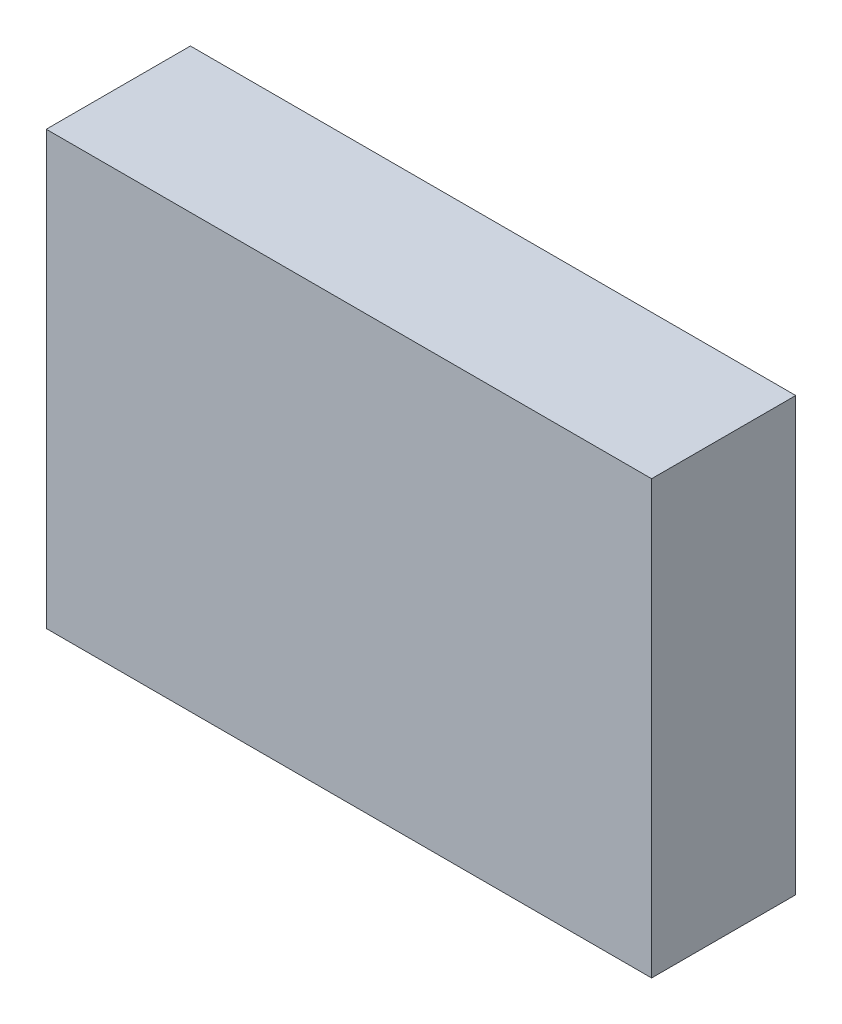
from build123d import *

# Parameters (mm, degrees)
SKETCH1_W           = 84
SKETCH1_H           = 60
BOSS_EXTRUDE1_DEPTH = 20


with BuildPart() as part:
    # Sketch1 → Boss-Extrude1 (new body)
    with BuildSketch(Plane.XY):
        with Locations((7.2359999, 5.170450478)):
            Rectangle(SKETCH1_W, SKETCH1_H)
    extrude(amount=BOSS_EXTRUDE1_DEPTH)


solid = part.part
